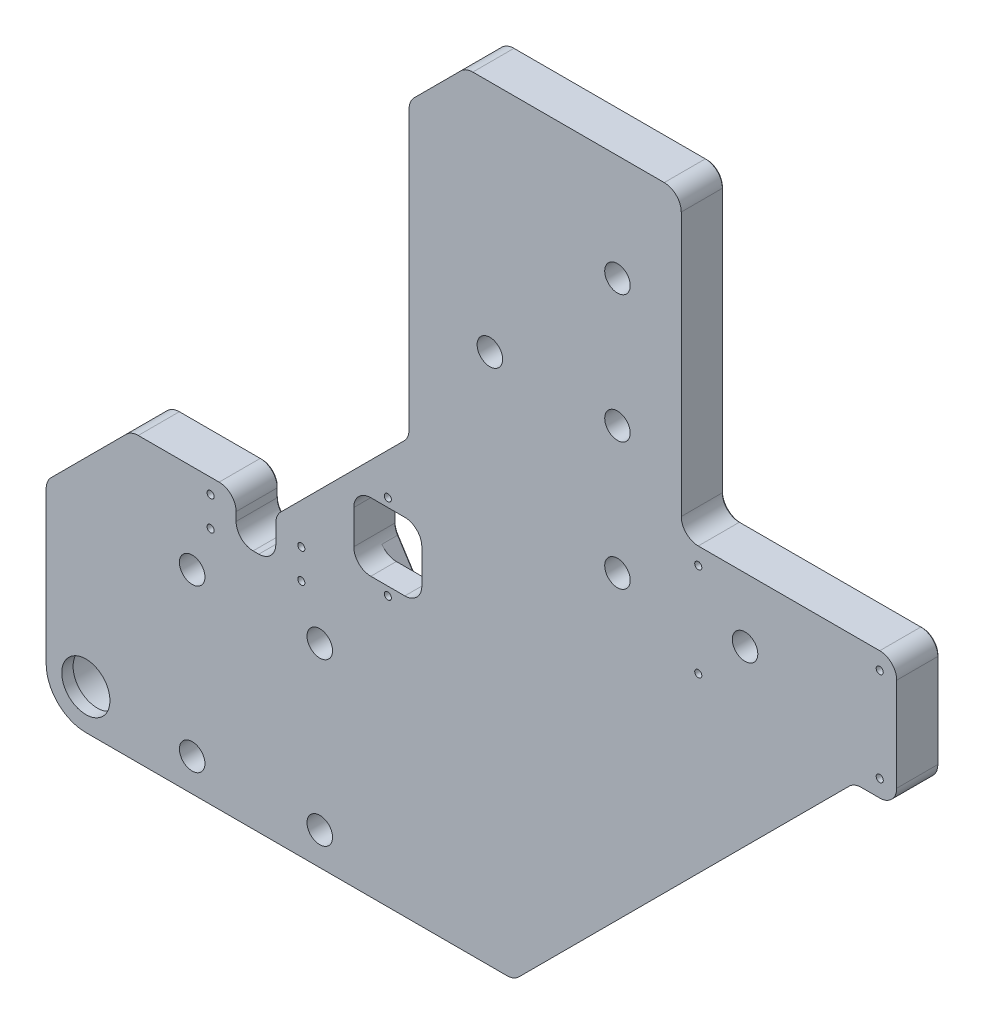
from build123d import *

# Parameters (mm, degrees)
BOSS_EXTRU_1_DEPTH                                 = 15
CHAMBRAGE_POUR_VIS_T_TE_HEXAGONALE_M81_D           = 9
CHAMBRAGE_POUR_VIS_T_TE_HEXAGONALE_M81_CBORE_D     = 15
CHAMBRAGE_POUR_VIS_T_TE_HEXAGONALE_M81_CBORE_DEPTH = 8.6
TAP_DRILL_FOR_M5_TAP1_D                            = 4.2
TAP_DRILL_FOR_M5_TAP1_DEPTH                        = 13
TAP_DRILL_FOR_M5_TAP1_TIP                          = 1.2618073
SKETCH25_W                                         = 14
SKETCH25_H                                         = 15
CUT_EXTRUDE6_DEPTH                                 = 16
CONG_1_R                                           = 6
SKETCH11_R                                         = 8.5
CUT_EXTRUDE1_DEPTH                                 = 16
SKETCH12_R                                         = 11
CUT_EXTRUDE2_DEPTH                                 = 11
SKETCH13_W                                         = 24
SKETCH13_H                                         = 24
CUT_EXTRUDE3_DEPTH                                 = 16
FILLET1_R                                          = 6
CUT_EXTRUDE4_DEPTH                                 = 6
FILLET3_R                                          = 14
TAP_DRILL_FOR_M3_TAP1_D                            = 2.5
CHAMFER1_SIZE                                      = 0.5
TAP_DRILL_FOR_M3_TAP2_D                            = 2.5
TAP_DRILL_FOR_M3_TAP3_D                            = 2.5
TROU_POUR_TARAUDAGE_POUR_TROU_TARAUD_M6_D          = 5
TROU_POUR_TARAUDAGE_POUR_TROU_TARAUD_M6_DEPTH      = 20
TROU_POUR_TARAUDAGE_POUR_TROU_TARAUD_M6_TIP        = 1.502151548


with BuildPart() as part:
    # Esquisse1 → Boss.-Extru.1 (new body)
    with BuildSketch(Plane.XY):
        Polygon((-21.072673536, 123.242590707), (54.927326464, 123.242590707), (54.927326464, 18.242590707), (130.927326464, 18.242590707), (130.927326464, -26.757409293), (115.927326464, -26.757409293), (-4.072673536, -146.757409293), (-169.072673536, -146.757409293), (-169.072673536, -76.757409293), (-139.072673536, -46.757409293), (-88.072673536, -46.757409293), (-41.072673536, 0.242590707), (-41.072673536, 103.242590707), align=None)
    extrude(amount=BOSS_EXTRU_1_DEPTH)

    # Chambrage pour vis à tête hexagonale M81 (through all)
    with Locations(Plane(origin=(0, 0, 0), x_dir=(-1, 0, 0), z_dir=(0, 0, -1))):
        with Locations((72.572673536, -78.257409293), (117.572673536, -78.257409293), (72.572673536, -135.257409293), (117.572673536, -135.257409293), (-32.427326464, 85.742590707), (-32.427326464, 40.742590707), (-32.427326464, -4.257409293), (-77.427326464, -4.257409293), (12.572673536, 40.742590707)):
            CounterBoreHole(CHAMBRAGE_POUR_VIS_T_TE_HEXAGONALE_M81_D / 2, CHAMBRAGE_POUR_VIS_T_TE_HEXAGONALE_M81_CBORE_D / 2, CHAMBRAGE_POUR_VIS_T_TE_HEXAGONALE_M81_CBORE_DEPTH)

    # Tap Drill for M5 Tap1
    with Locations(Plane(origin=(0, -146.757409293, 0), x_dir=(-1, 0, 0), z_dir=(0, -1, 0))):
        with Locations((13.072673536, -7.5)):
            Hole(TAP_DRILL_FOR_M5_TAP1_D / 2, depth=TAP_DRILL_FOR_M5_TAP1_DEPTH)
            with Locations((0, 0, -(TAP_DRILL_FOR_M5_TAP1_DEPTH + TAP_DRILL_FOR_M5_TAP1_TIP / 2))):  # 118° drill point
                Cone(0, TAP_DRILL_FOR_M5_TAP1_D / 2, TAP_DRILL_FOR_M5_TAP1_TIP, mode=Mode.SUBTRACT)

    # Sketch25 → Cut-Extrude6 (cut, through all)
    with BuildSketch(Plane(origin=(0, 0, 0), x_dir=(-1, 0, 0), z_dir=(0, 0, -1))):
        with Locations((95.072673536, -54.257409293)):
            Rectangle(SKETCH25_W, SKETCH25_H)
    extrude(amount=-CUT_EXTRUDE6_DEPTH, mode=Mode.SUBTRACT)

    # Congé1
    cong_1_edges = [part.edges().sort_by_distance(p)[0] for p in [
        (-88.072673536, -61.757409293, 7.5),
        (-102.072673536, -46.757409293, 7.5),
        (-102.072673536, -61.757409293, 7.5),
        (54.927326464, 18.242590707, 7.5),
        (130.927326464, 18.242590707, 7.5),
        (130.927326464, -26.757409293, 7.5),
        (115.927326464, -26.757409293, 7.5),
        (-4.072673536, -146.757409293, 7.5),
        (-169.072673536, -76.757409293, 7.5),
        (-139.072673536, -46.757409293, 7.5),
        (-88.072673536, -46.757409293, 7.5),
        (-41.072673536, 0.242590707, 7.5),
        (-41.072673536, 103.242590707, 7.5),
        (-21.072673536, 123.242590707, 7.5),
        (54.927326464, 123.242590707, 7.5),
    ]]
    fillet(cong_1_edges, radius=CONG_1_R)

    # Sketch11 → Cut-Extrude1 (cut, through all)
    with BuildSketch(Plane(origin=(0, 0, 0), x_dir=(-1, 0, 0), z_dir=(0, 0, -1))):
        with Locations((155.072673536, -132.757409293)):
            Circle(SKETCH11_R)
    extrude(amount=-CUT_EXTRUDE1_DEPTH, mode=Mode.SUBTRACT)

    # Sketch12 → Cut-Extrude2 (cut)
    with BuildSketch(Plane(origin=(0, 0, 0), x_dir=(-1, 0, 0), z_dir=(0, 0, -1))):
        with Locations((155.072673536, -132.757409293)):
            Circle(SKETCH12_R)
    extrude(amount=-CUT_EXTRUDE2_DEPTH, mode=Mode.SUBTRACT)

    # Sketch13 → Cut-Extrude3 (cut, through all)
    with BuildSketch(Plane(origin=(0, 0, 0), x_dir=(-1, 0, 0), z_dir=(0, 0, -1))):
        with Locations((48.572673536, -36.757409293)):
            Rectangle(SKETCH13_W, SKETCH13_H)
    extrude(amount=-CUT_EXTRUDE3_DEPTH, mode=Mode.SUBTRACT)

    # Fillet1
    fillet1_edges = [part.edges().sort_by_distance(p)[0] for p in [
        (-36.572673536, -48.757409293, 7.5),
        (-36.572673536, -24.757409293, 7.5),
        (-60.572673536, -24.757409293, 7.5),
        (-60.572673536, -48.757409293, 7.5),
    ]]
    fillet(fillet1_edges, radius=FILLET1_R)

    # Sketch14 → Cut-Extrude4 (cut)
    with BuildSketch(Plane(origin=(0, 0, 0), x_dir=(-1, 0, 0), z_dir=(0, 0, -1))):
        with BuildLine():
            Line((53.794093198, -18.414240629), (59.625660306, -27.52208478))
            ThreePointArc((59.625660306, -27.52208478), (60.33105528, -29.071870895), (60.572673536, -30.757409293))
            Line((60.572673536, -30.757409293), (60.572673536, -42.757409293))
            ThreePointArc((60.572673536, -42.757409293), (60.33105528, -44.442947691), (59.625660306, -45.992733806))
            Line((59.625660306, -45.992733806), (53.794093198, -55.100577956))
            ThreePointArc((53.794093198, -55.100577956), (48.572673536, -57.957409293), (43.351253874, -55.100577956))
            Line((43.351253874, -55.100577956), (37.519686767, -45.992733806))
            ThreePointArc((37.519686767, -45.992733806), (36.814291792, -44.442947691), (36.572673536, -42.757409293))
            Line((36.572673536, -42.757409293), (36.572673536, -30.757409293))
            ThreePointArc((36.572673536, -30.757409293), (36.814291792, -29.071870895), (37.519686767, -27.52208478))
            Line((37.519686767, -27.52208478), (43.351253874, -18.414240629))
            ThreePointArc((43.351253874, -18.414240629), (48.572673536, -15.557409293), (53.794093198, -18.414240629))
        make_face()
    extrude(amount=-CUT_EXTRUDE4_DEPTH, mode=Mode.SUBTRACT)

    # Fillet3
    fillet3_edges = [part.edges().sort_by_distance(p)[0] for p in [
        (-169.072673536, -146.757409293, 7.5),
    ]]
    fillet(fillet3_edges, radius=FILLET3_R)

    # Tap Drill for M3 Tap1 (through all)
    with Locations(Plane(origin=(0, 0, 6), x_dir=(-1, 0, 0), z_dir=(0, 0, -1))):
        with Locations((48.572673536, -21.757409293), (48.572673536, -51.757409293)):
            Hole(TAP_DRILL_FOR_M3_TAP1_D / 2)

    # Chamfer1
    chamfer1_edges = [part.edges().sort_by_distance(p)[0] for p in [
        (-102.072673536, -54.257409293, 0),
        (-95.072673536, -61.757409293, 0),
        (-88.072673536, -52.50004998, 0),
        (-122.330032849, -46.757409293, 0),
        (-64.572673536, -23.257409293, 0),
        (-41.072673536, 51.742590707, 0),
        (-31.072673536, 113.242590707, 0),
        (15.169967151, 123.242590707, 0),
        (54.927326464, 70.742590707, 0),
        (92.927326464, 18.242590707, 0),
        (130.927326464, -4.257409293, 0),
        (121.669967151, -26.757409293, 0),
        (55.927326464, -86.757409293, 0),
        (-169.072673536, -106.00004998, 0),
        (-154.072673536, -61.757409293, 0),
        (53.169967151, 121.485231394, 0),
        (-20.883492756, 122.785867902, 0),
        (-138.883492756, -47.214132098, 0),
        (-168.615950731, -76.946590073, 0),
        (-40.615950731, 103.053409927, 0),
        (129.169967151, 16.485231394, 0),
        (129.169967151, -25.00004998, 0),
        (-4.261854316, -146.300686488, 0),
        (-87.615950731, -46.946590073, 0),
        (-103.830032849, -48.514768606, 0),
        (-100.315314223, -60.00004998, 0),
        (-89.830032849, -60.00004998, 0),
        (116.116507244, -27.214132098, 0),
        (-41.529396341, 0.431771487, 0),
        (56.684685777, 19.99995002, 0),
        (-144.072673536, -132.757409293, 0),
        (-60.572673536, -36.757409293, 0),
        (-36.572673536, -36.757409293, 0),
        (-60.33105528, -44.442947691, 0),
        (-36.814291792, -29.071870895, 0),
        (-60.33105528, -29.071870895, 0),
        (-36.814291792, -44.442947691, 0),
        (-56.709876752, -50.546655881, 0),
        (-40.43547032, -50.546655881, 0),
        (-48.572673536, -57.957409293, 0),
        (-40.43547032, -22.968162704, 0),
        (-56.709876752, -22.968162704, 0),
        (-48.572673536, -15.557409293, 0),
        (-80.815314223, -146.757409293, 0),
        (-164.972168473, -142.656904229, 0),
        (-5.072673536, 40.742590707, 0),
        (84.927326464, -4.257409293, 0),
        (39.927326464, -4.257409293, 0),
        (39.927326464, 40.742590707, 0),
        (39.927326464, 85.742590707, 0),
        (-110.072673536, -135.257409293, 0),
        (-65.072673536, -135.257409293, 0),
        (-110.072673536, -78.257409293, 0),
        (-65.072673536, -78.257409293, 0),
    ]]
    chamfer(chamfer1_edges, length=CHAMFER1_SIZE)

    # Tap Drill for M3 Tap2 (through all)
    with Locations(Plane(origin=(0, 0, 0), x_dir=(-1, 0, 0), z_dir=(0, 0, -1))):
        with Locations((-124.927326464, 12.242590707), (-124.927326464, -20.757409293), (-60.927326464, 12.242590707), (-60.927326464, -20.757409293)):
            Hole(TAP_DRILL_FOR_M3_TAP2_D / 2)

    # Tap Drill for M3 Tap3 (through all)
    with Locations(Plane.XY.offset(15)):
        with Locations((-111.072673536, -52.057409293), (-111.072673536, -62.457409293), (-79.072673536, -62.457409293), (-79.072673536, -52.057409293)):
            Hole(TAP_DRILL_FOR_M3_TAP3_D / 2)

    # Trou pour taraudage pour trou taraudé M61
    with Locations(Plane(origin=(0, -146.757409293, 0), x_dir=(-1, 0, 0), z_dir=(0, -1, 0))):
        with Locations((35.615798493, -7.5), (85.615798493, -7.5)):
            Hole(TROU_POUR_TARAUDAGE_POUR_TROU_TARAUD_M6_D / 2, depth=TROU_POUR_TARAUDAGE_POUR_TROU_TARAUD_M6_DEPTH)
            with Locations((0, 0, -(TROU_POUR_TARAUDAGE_POUR_TROU_TARAUD_M6_DEPTH + TROU_POUR_TARAUDAGE_POUR_TROU_TARAUD_M6_TIP / 2))):  # 118° drill point
                Cone(0, TROU_POUR_TARAUDAGE_POUR_TROU_TARAUD_M6_D / 2, TROU_POUR_TARAUDAGE_POUR_TROU_TARAUD_M6_TIP, mode=Mode.SUBTRACT)


solid = part.part
